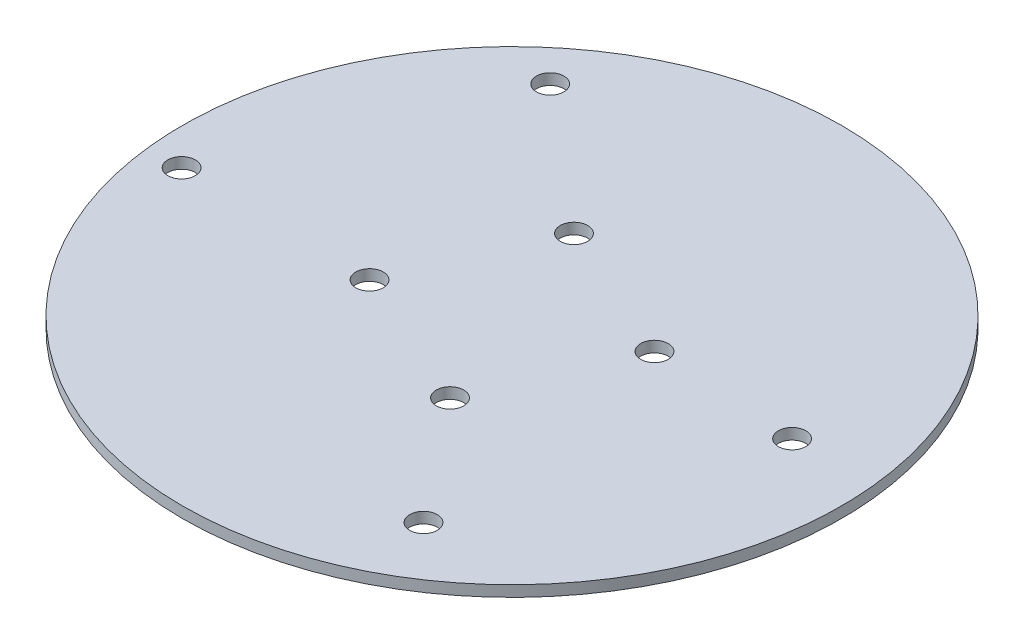
from build123d import *

# Parameters (mm, degrees)
SKETCH1_R           = 76.2
BOSS_EXTRUDE1_DEPTH = 2.54
SKETCH2_R           = 3.175
CUT_EXTRUDE1_DEPTH  = 2.54
SKETCH4_R           = 3.175
CUT_EXTRUDE3_DEPTH  = 3.54


with BuildPart() as part:
    # Sketch1 → Boss-Extrude1 (new body)
    with BuildSketch(Plane(origin=(0, 0, 0), x_dir=(1, 0, 0), z_dir=(0, 1, 0))):
        Circle(SKETCH1_R)
    extrude(amount=BOSS_EXTRUDE1_DEPTH)

    # Sketch2 → Cut-Extrude1 (cut)
    with BuildSketch(Plane.XZ):
        with Locations((-67.814061825, 8.585318756)):
            Circle(SKETCH2_R)
        with Locations((-41.97979671, -50.809492852)):
            Circle(SKETCH2_R)
        with Locations((57.01155597, -7.752384327)):
            Circle(SKETCH2_R)
        with Locations((31.177290855, 51.642427281)):
            Circle(SKETCH2_R)
    extrude(amount=-CUT_EXTRUDE1_DEPTH, mode=Mode.SUBTRACT)

    # Sketch4 → Cut-Extrude3 (cut, through all)
    with BuildSketch(Plane(origin=(0, 2.54, 0), x_dir=(1, 0, 0), z_dir=(0, 1, 0))):
        with Locations((-9.306231375, 23.633748277)):
            Circle(SKETCH4_R)
        with Locations((23.633748277, 9.306231375)):
            Circle(SKETCH4_R)
        with Locations((9.306231375, -23.633748277)):
            Circle(SKETCH4_R)
        with Locations((-23.633748277, -9.306231375)):
            Circle(SKETCH4_R)
    extrude(amount=-CUT_EXTRUDE3_DEPTH, mode=Mode.SUBTRACT)


solid = part.part
